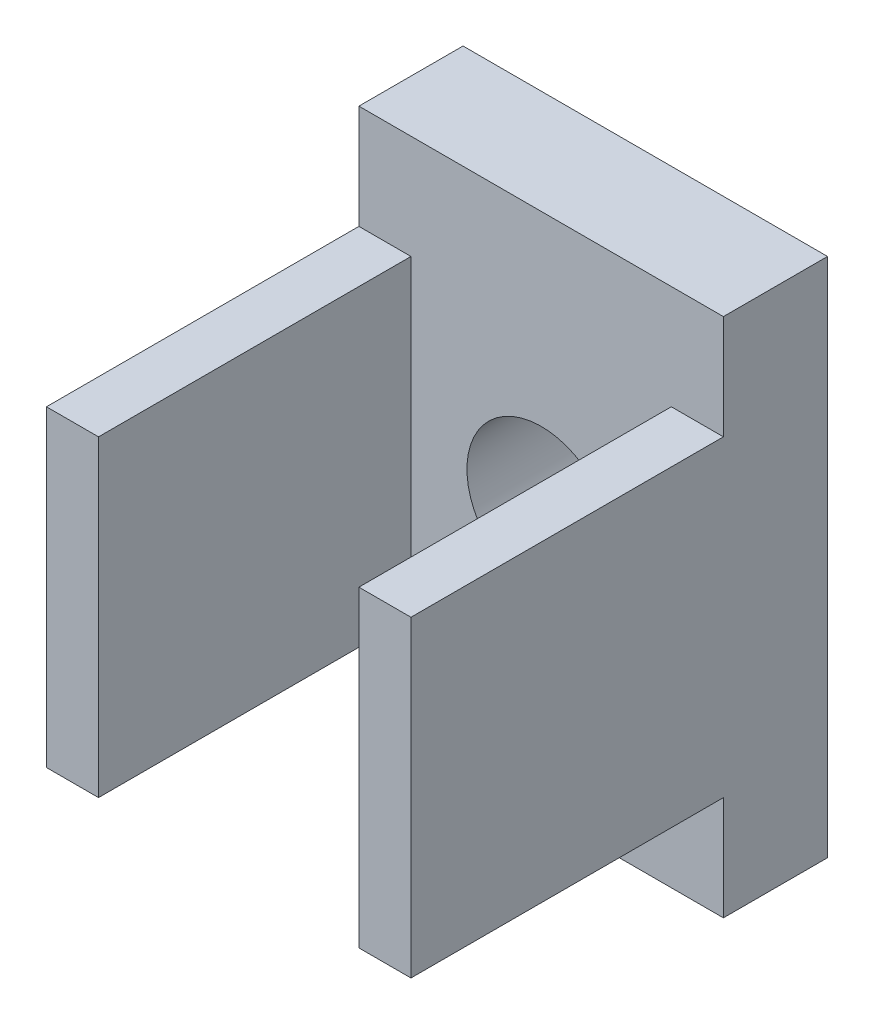
from build123d import *

# Parameters (mm, degrees)
SKETCH1_W           = 7
SKETCH1_H           = 10
BOSS_EXTRUDE1_DEPTH = 2
SKETCH2_R           = 1.425
CUT_EXTRUDE1_DEPTH  = 2
SKETCH3_W           = 1
SKETCH3_H           = 6
BOSS_EXTRUDE2_DEPTH = 6


with BuildPart() as part:
    # Sketch1 → Boss-Extrude1 (new body)
    with BuildSketch(Plane.XY):
        Rectangle(SKETCH1_W, SKETCH1_H)
    extrude(amount=BOSS_EXTRUDE1_DEPTH)

    # Sketch2 → Cut-Extrude1 (cut)
    with BuildSketch(Plane.XY.offset(2)):
        Circle(SKETCH2_R)
    extrude(amount=-CUT_EXTRUDE1_DEPTH, mode=Mode.SUBTRACT)

    # Sketch3 → Boss-Extrude2 (add)
    with BuildSketch(Plane.XY.offset(2)):
        with Locations((-3, 0)):
            Rectangle(SKETCH3_W, SKETCH3_H)
        with Locations((3, 0)):
            Rectangle(SKETCH3_W, SKETCH3_H)
    extrude(amount=BOSS_EXTRUDE2_DEPTH)


solid = part.part
